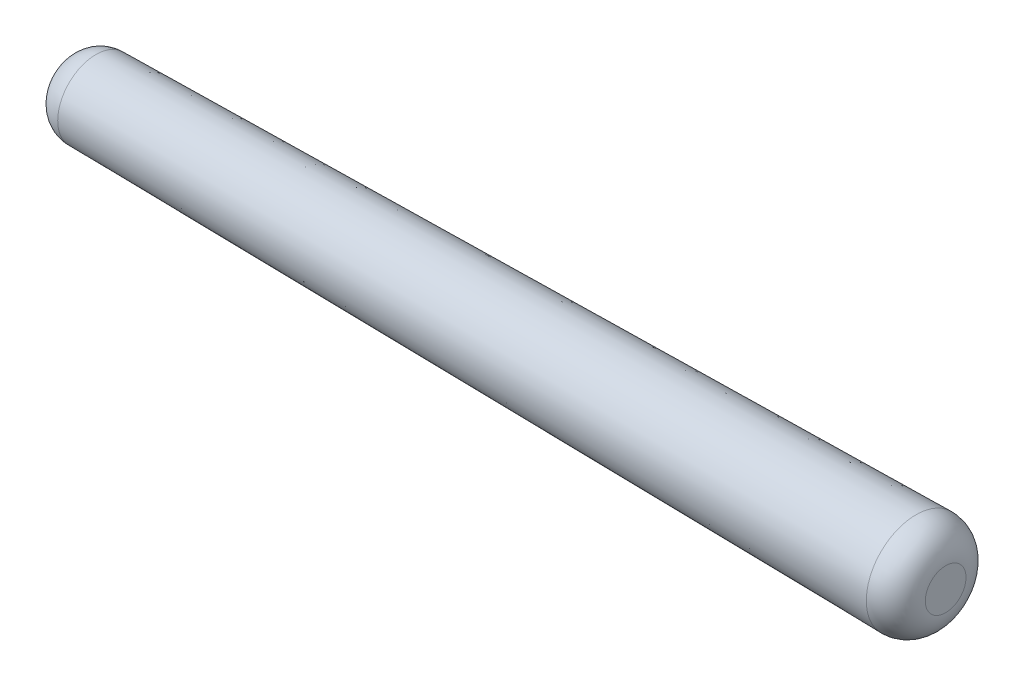
from build123d import *

# Parameters (mm, degrees)
FILLET1_R = 0.4


with BuildPart() as part:
    # Sketch2 → Revolve1 (revolve)
    with BuildSketch(Plane.XY):
        Polygon((6, 0), (-6, 0), (-6, -0.516218751), (6, -0.683781249), align=None)
    revolve(axis=Axis((6, 0, 0), (-1, 0, 0)))

    # Fillet1
    fillet1_edges = [part.edges().sort_by_distance(p)[0] for p in [
        (6, 0.683781249, 0),
        (-6, 0.516218751, 0),
    ]]
    fillet(fillet1_edges, radius=FILLET1_R)


solid = part.part
